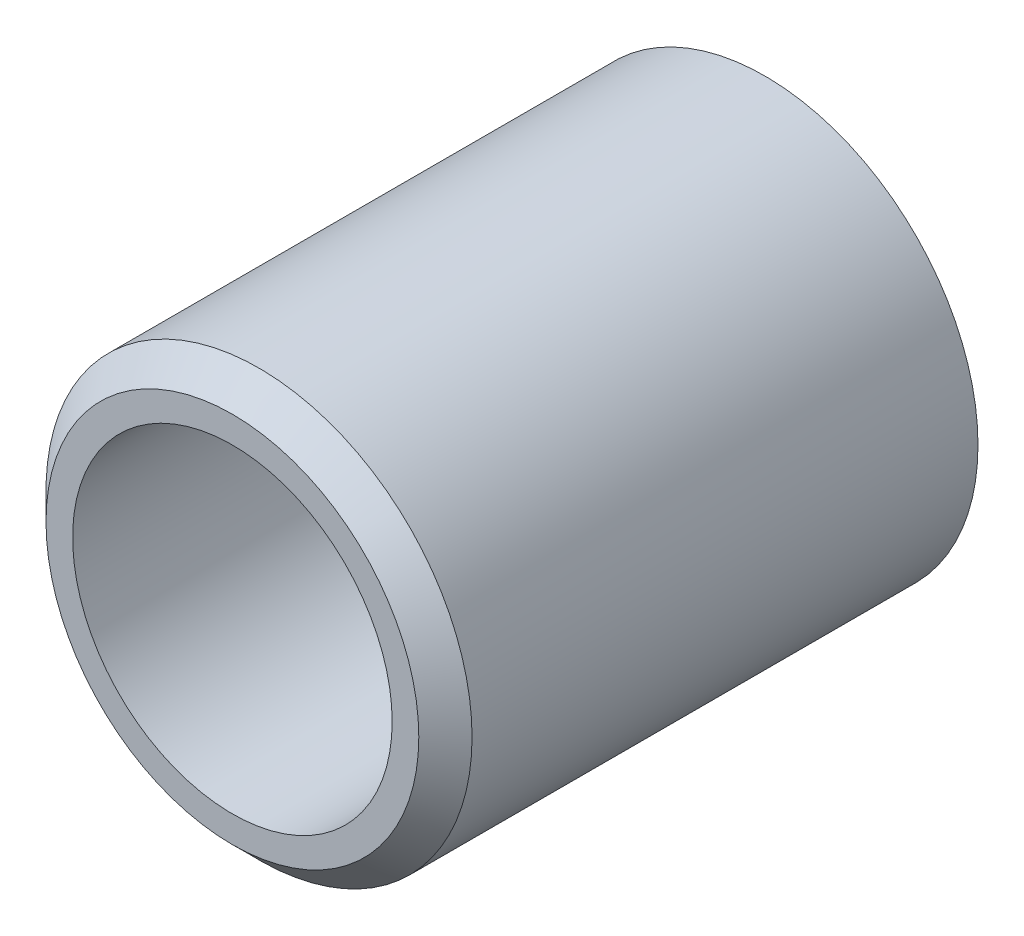
from build123d import *


with BuildPart() as part:
    # 草圖2 → 旋轉1 (revolve)
    with BuildSketch(Plane(origin=(0, 0, 0), x_dir=(0, 0, -1), z_dir=(1, 0, 0))):
        Polygon((0.5, 4), (10, 4), (10, 3.5), (9.5, 3), (0, 3), (0, 3.5), align=None)
    revolve(axis=Axis((0, 0, 9.436936937), (0, 0, -1)))


solid = part.part
